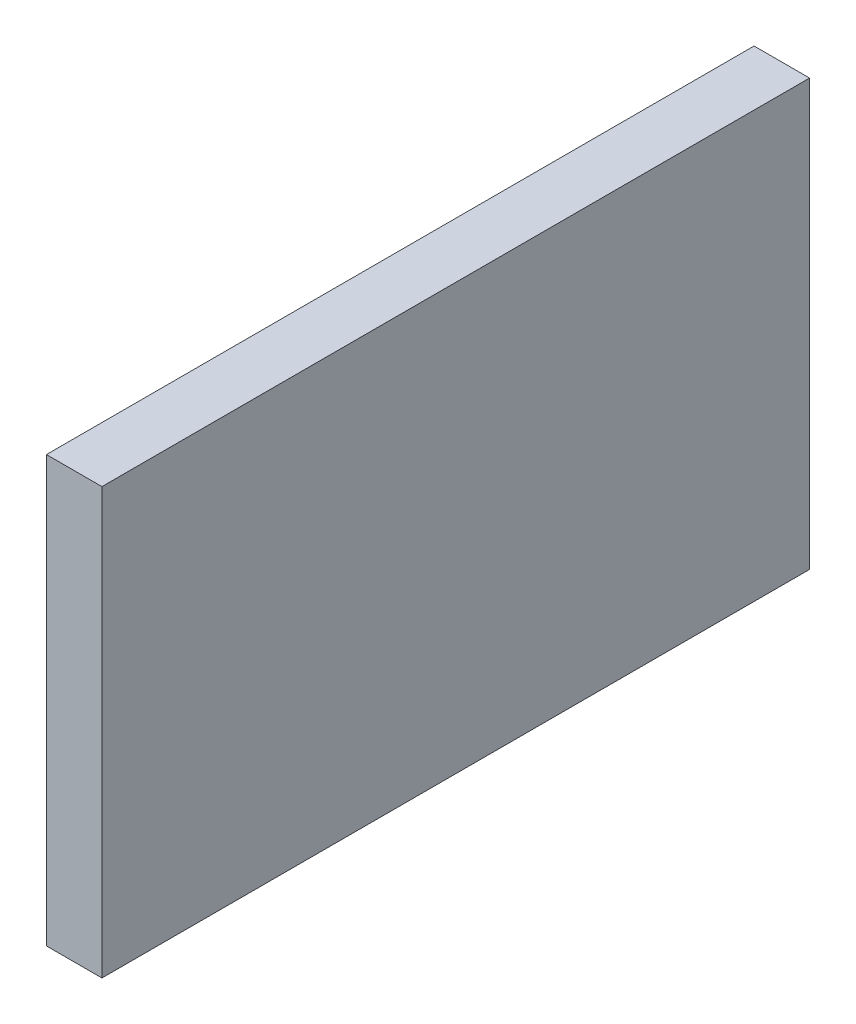
from build123d import *

# Parameters (mm, degrees)
SKETCH1_W           = 3
SKETCH1_H           = 23.003536126
BOSS_EXTRUDE1_DEPTH = 38.25


with BuildPart() as part:
    # Sketch1 → Boss-Extrude1 (new body)
    with BuildSketch(Plane.XY.offset(37.780531955)):
        with Locations((9.857732215, 33.325057501)):
            Rectangle(SKETCH1_W, SKETCH1_H)
    extrude(amount=BOSS_EXTRUDE1_DEPTH)


solid = part.part
